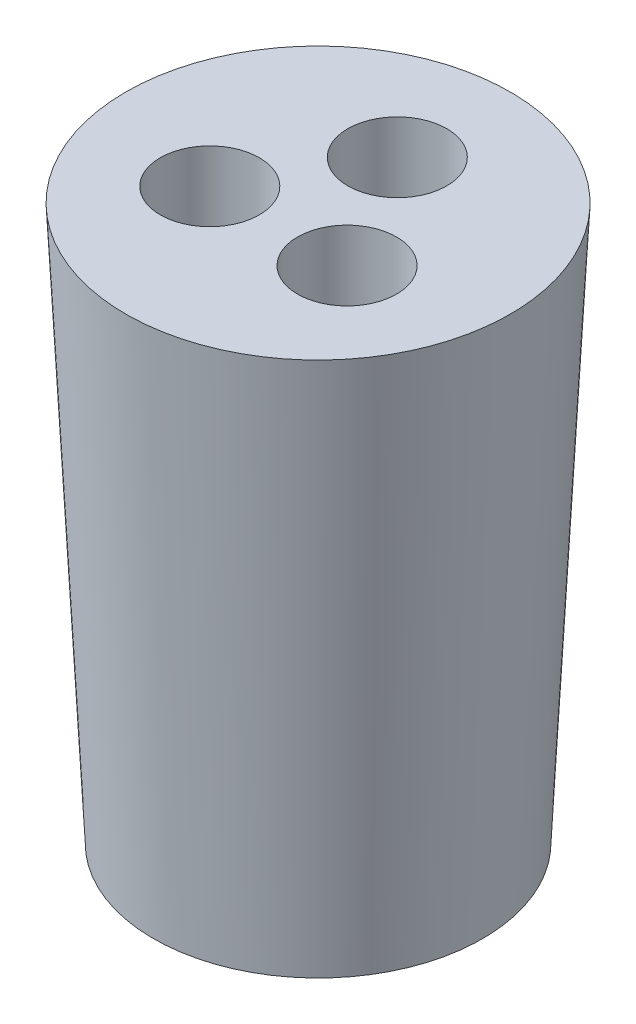
from build123d import *

# Parameters (mm, degrees)
SKETCH2_R               = 3.175
CUT_EXTRUDE1_DEPTH      = 1
CUT_EXTRUDE1_DEPTH_BACK = 36.56


with BuildPart() as part:
    # Sketch1 → Revolve1 (revolve)
    with BuildSketch(Plane.XY):
        Polygon((10.55, 0), (12.328, 35.56), (0, 35.56), (0, 0), align=None)
    revolve(axis=Axis((0, 35.56, 0), (0, -1, 0)))

    # Sketch2 → Cut-Extrude1 (cut, two sides)
    with BuildSketch(Plane(origin=(0, 35.56, 0), x_dir=(1, 0, 0), z_dir=(0, 1, 0))) as cut_extrude1_sk:
        with Locations((0, 5.08)):
            Circle(SKETCH2_R)
        with Locations((4.399409051, -2.54)):
            Circle(SKETCH2_R)
        with Locations((-4.399409051, -2.54)):
            Circle(SKETCH2_R)
    extrude(amount=CUT_EXTRUDE1_DEPTH, mode=Mode.SUBTRACT)
    extrude(cut_extrude1_sk.sketch, amount=-CUT_EXTRUDE1_DEPTH_BACK, mode=Mode.SUBTRACT)


solid = part.part
